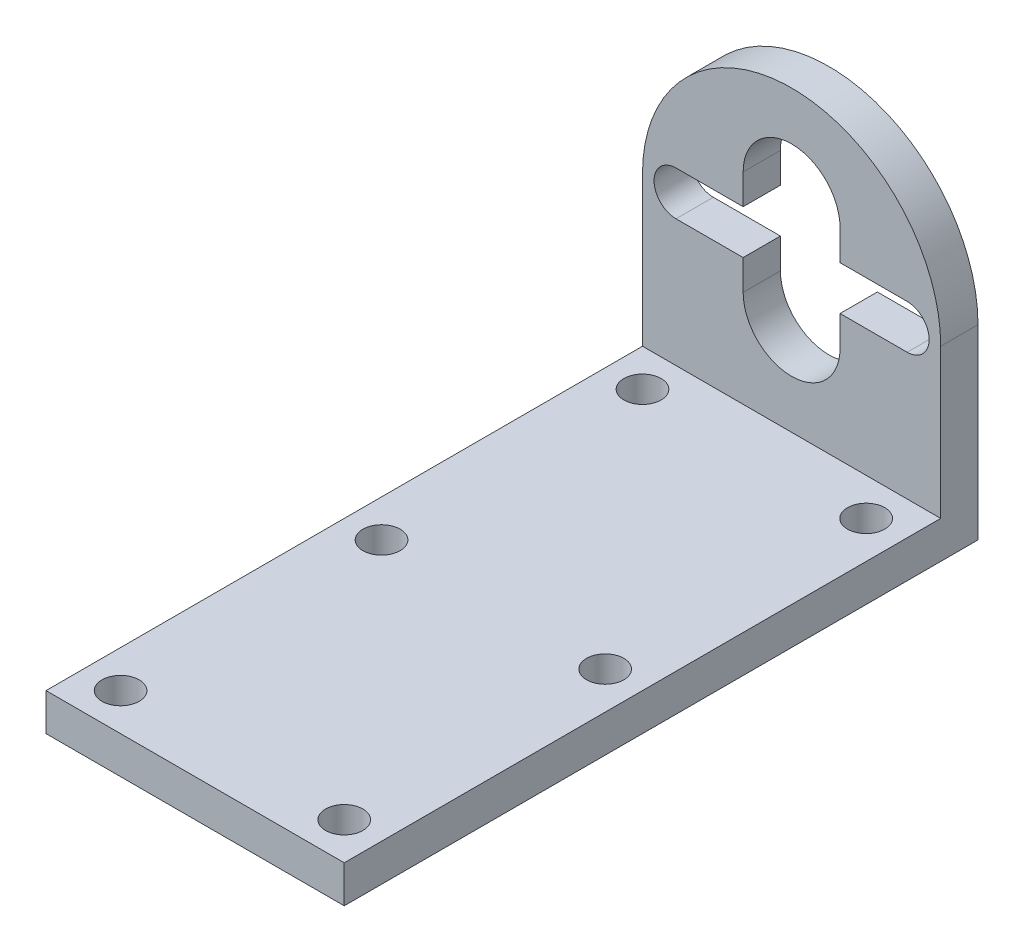
from build123d import *

# Parameters (mm, degrees)
BOSS_EXTRUDE1_DEPTH = 5
SKETCH3_W           = 40
SKETCH3_H           = 5
BOSS_EXTRUDE2_DEPTH = 80
SKETCH4_R           = 2.5
CUT_EXTRUDE1_DEPTH  = 10
CUT_EXTRUDE2_DEPTH  = 10


with BuildPart() as part:
    # Sketch2 → Boss-Extrude1 (new body)
    with BuildSketch(Plane.XY):
        with BuildLine():
            Line((20, 0), (20, -25))
            Line((20, -25), (-20, -25))
            Line((-20, -25), (-20, 0))
            ThreePointArc((-20, 0), (0, 20), (20, 0))
        make_face()
        with BuildLine():
            Line((-15.5, 2.95), (15.5, 2.95))
            ThreePointArc((15.5, 2.95), (18.45, 0), (15.5, -2.95))
            Line((15.5, -2.95), (-15.5, -2.95))
            ThreePointArc((-15.5, -2.95), (-18.45, 0), (-15.5, 2.95))
        make_face(mode=Mode.SUBTRACT)
    extrude(amount=BOSS_EXTRUDE1_DEPTH)

    # Sketch3 → Boss-Extrude2 (add)
    with BuildSketch(Plane.XY.offset(5)):
        with Locations((0, -22.5)):
            Rectangle(SKETCH3_W, SKETCH3_H)
    extrude(amount=BOSS_EXTRUDE2_DEPTH)

    # Sketch4 → Cut-Extrude1 (cut)
    with BuildSketch(Plane(origin=(0, -20, 0), x_dir=(1, 0, 0), z_dir=(0, 1, 0))):
        with Locations((-15, -10)):
            Circle(SKETCH4_R)
        with Locations((15, -10)):
            Circle(SKETCH4_R)
        with Locations((15, -80)):
            Circle(SKETCH4_R)
        with Locations((-15, -80)):
            Circle(SKETCH4_R)
        with Locations((-15, -45)):
            Circle(SKETCH4_R)
        with Locations((15, -45)):
            Circle(SKETCH4_R)
    extrude(amount=-CUT_EXTRUDE1_DEPTH, mode=Mode.SUBTRACT)

    # Sketch5 → Cut-Extrude2 (cut)
    with BuildSketch(Plane.XY.offset(5)):
        with BuildLine():
            Line((6.5, 7), (6.5, -7))
            ThreePointArc((6.5, -7), (0, -13.5), (-6.5, -7))
            Line((-6.5, -7), (-6.5, 7))
            ThreePointArc((-6.5, 7), (0, 13.5), (6.5, 7))
        make_face()
    extrude(amount=-CUT_EXTRUDE2_DEPTH, mode=Mode.SUBTRACT)


solid = part.part
